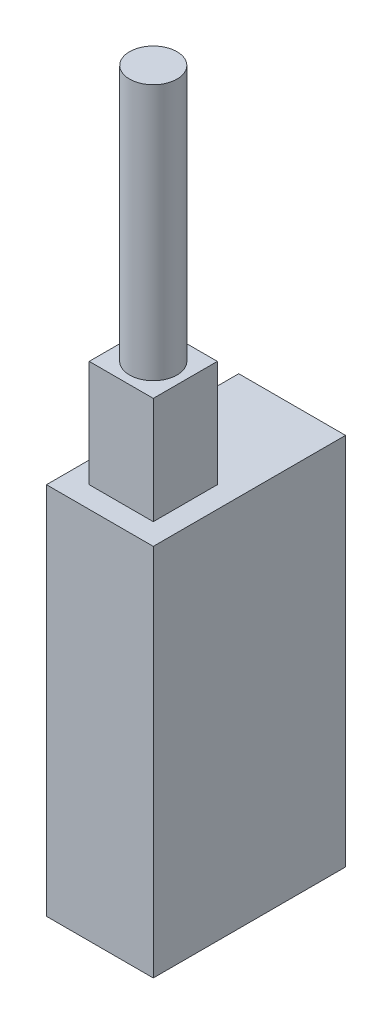
from build123d import *

# Parameters (mm, degrees)
SKETCH1_W           = 20
SKETCH1_H           = 36
BOSS_EXTRUDE1_DEPTH = 70
SKETCH2_W           = 12
SKETCH2_H           = 12
BOSS_EXTRUDE2_DEPTH = 20
SKETCH3_R           = 4.445
BOSS_EXTRUDE3_DEPTH = 48


with BuildPart() as part:
    # Sketch1 → Boss-Extrude1 (new body)
    with BuildSketch(Plane(origin=(0, 0, 0), x_dir=(1, 0, 0), z_dir=(0, 1, 0))):
        Rectangle(SKETCH1_W, SKETCH1_H)
    extrude(amount=BOSS_EXTRUDE1_DEPTH)

    # Sketch2 → Boss-Extrude2 (add)
    with BuildSketch(Plane(origin=(0, 70, 0), x_dir=(1, 0, 0), z_dir=(0, 1, 0))):
        with Locations((0, -8)):
            Rectangle(SKETCH2_W, SKETCH2_H)
    extrude(amount=BOSS_EXTRUDE2_DEPTH)

    # Sketch3 → Boss-Extrude3 (add)
    with BuildSketch(Plane(origin=(0, 90, 0), x_dir=(1, 0, 0), z_dir=(0, 1, 0))):
        with Locations((0, -8)):
            Circle(SKETCH3_R)
    extrude(amount=BOSS_EXTRUDE3_DEPTH)


solid = part.part
